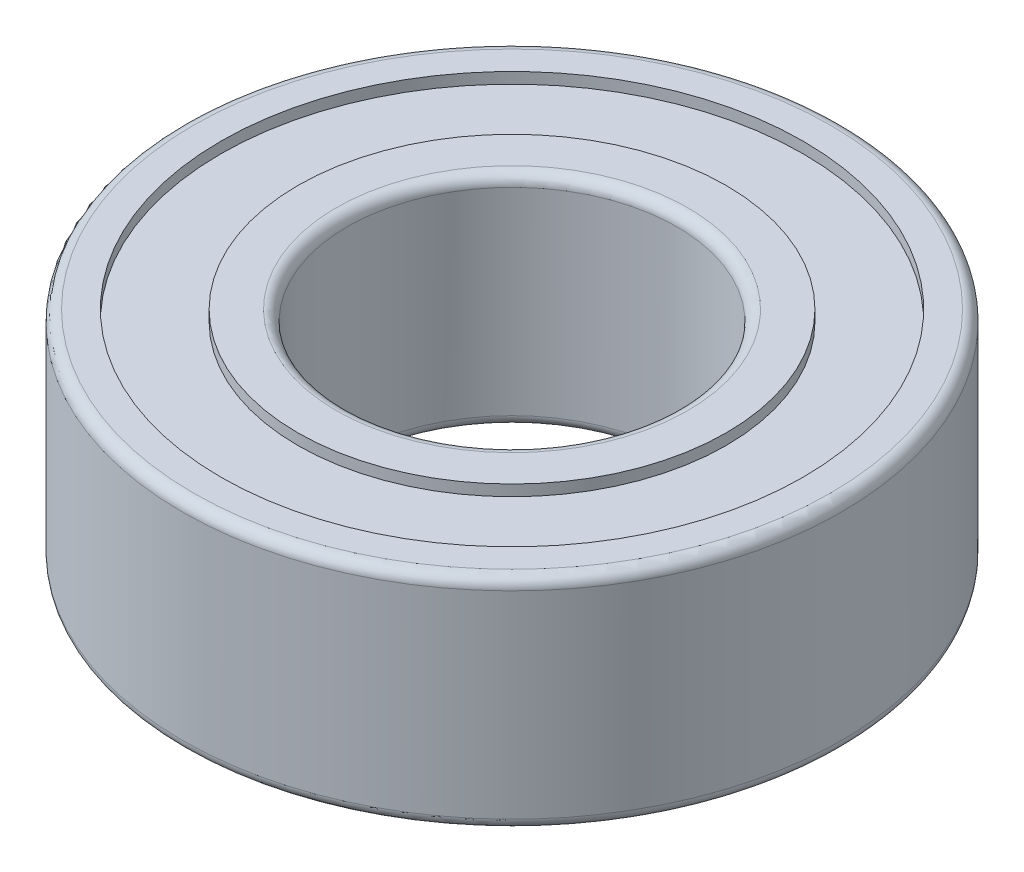
from build123d import *

# Parameters (mm, degrees)
FILLET1_R            = 0.2
FILLET1_OF_MIRROR1_R = 0.2


with BuildPart() as part:
    # Sketch1 → Revolve1 (revolve)
    with BuildSketch(Plane(origin=(0, 0, 0), x_dir=(0, 0, -1), z_dir=(1, 0, 0))):
        Polygon((-6, 0), (-6, 2), (-5.3, 2), (-5.3, 1.8), (-3.9, 1.8), (-3.9, 2), (-3, 2), (-3, 0), align=None)
    revolve1 = revolve(axis=Axis((0, 15.203883495, 0), (0, -1, 0)))

    # Fillet1
    fillet1_edges = [part.edges().sort_by_distance(p)[0] for p in [
        (0, 2, -3),
        (0, 2, -6),
    ]]
    fillet(fillet1_edges, radius=FILLET1_R)

    # Mirror1: Revolve1 across plane
    add(revolve1.mirror(Plane.ZX))

    # Fillet1 of Mirror1
    fillet1_of_mirror1_edges = [part.edges().sort_by_distance(p)[0] for p in [
        (0, -2, -3),
        (0, -2, -6),
    ]]
    fillet(fillet1_of_mirror1_edges, radius=FILLET1_OF_MIRROR1_R)


solid = part.part
